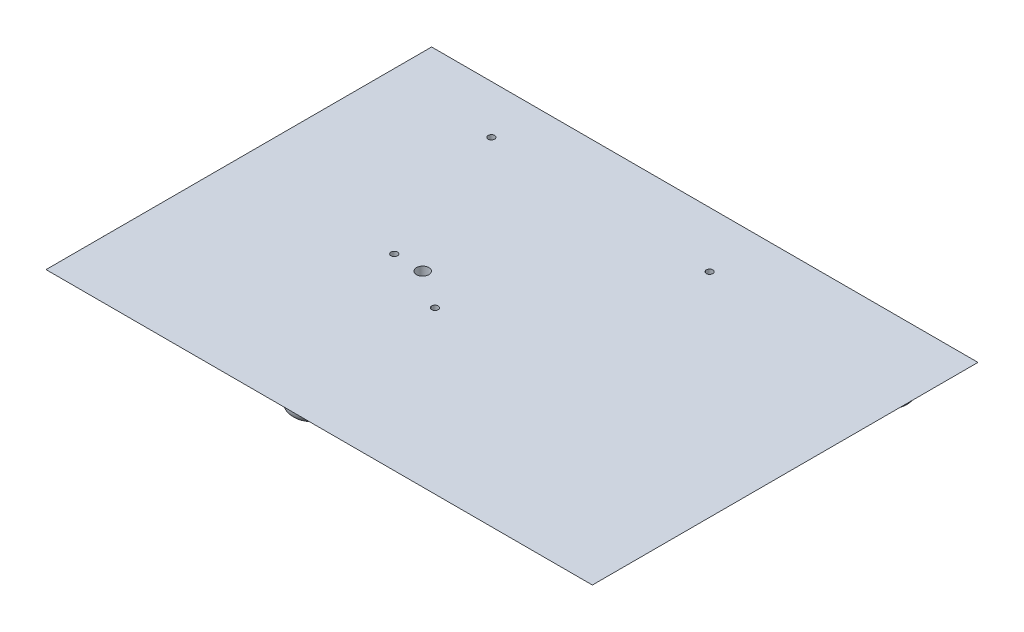
from build123d import *

# Parameters (mm, degrees)
SKETCH3_W           = 260
SKETCH3_H           = 183.5
SKETCH1_W           = 248
SKETCH1_H           = 175
SKETCH1_5_R         = 1.564169695
CUT_EXTRUDE1_DEPTH  = 6
SKETCH1_6_R         = 1.56
SKETCH1_6_R_2       = 2.946919111
CUT_EXTRUDE2_DEPTH  = 6
SKETCH1_7_R         = 1.56
SKETCH1_7_R_2       = 3.675
SKETCH1_7_R_3       = 1.564169695
SKETCH1_7_R_4       = 5.43
SKETCH1_7_R_5       = 2.946919111
BOSS_EXTRUDE2_DEPTH = 1
SKETCH1_9_R         = 1.56
CUT_EXTRUDE9_DEPTH  = 10
SKETCH1_10_R        = 1.563792904
CUT_EXTRUDE11_DEPTH = 10
SKETCH1_11_R        = 9.9
BOSS_EXTRUDE3_DEPTH = 12.5
FILLET1_R           = 5


with BuildPart() as part:
    # Sketch3 → Loft2 section 0
    with BuildSketch(Plane(origin=(0, 6, 0), x_dir=(1, 0, 0), z_dir=(0, 1, 0))):
        with Locations((105.714567309, -62.790792315)):
            Rectangle(SKETCH3_W, SKETCH3_H)
    # Sketch1 → Loft2 section 1
    with BuildSketch(Plane(origin=(0, 0, 0), x_dir=(1, 0, 0), z_dir=(0, 1, 0))):
        with Locations((105.463499551, -60.547933158)):
            Rectangle(SKETCH1_W, SKETCH1_H)
    loft()

    # Sketch1_5 → Cut-Extrude1 (cut)
    with BuildSketch(Plane(origin=(0, 0, 0), x_dir=(1, 0, 0), z_dir=(0, 1, 0))):
        with Locations((52.125403534, -65.240953474)):
            Circle(SKETCH1_5_R)
    extrude(amount=CUT_EXTRUDE1_DEPTH, mode=Mode.SUBTRACT)

    # Sketch1_6 → Cut-Extrude2 (cut)
    with BuildSketch(Plane(origin=(0, 0, 0), x_dir=(1, 0, 0), z_dir=(0, 1, 0))):
        with Locations((27.163499551, 5.952066842)):
            Circle(SKETCH1_6_R)
        with Locations((65.97433474, -65.547933158)):
            Circle(SKETCH1_6_R_2)
    extrude(amount=CUT_EXTRUDE2_DEPTH, mode=Mode.SUBTRACT)

    # Sketch1_7 → Boss-Extrude2 (add)
    with BuildSketch(Plane(origin=(0, 0, 0), x_dir=(1, 0, 0), z_dir=(0, 1, 0))):
        with BuildLine():
            ThreePointArc((30.764919641, 6.683776027), (23.488499551, 5.952066842), (30.764919641, 5.220357657))
            Line((30.764919641, 5.220357657), (30.764919641, 6.683776027))
        make_face()
        with Locations((27.163499551, 5.952066842)):
            Circle(SKETCH1_7_R, mode=Mode.SUBTRACT)
        with Locations((52.125403534, -65.240953474)):
            Circle(SKETCH1_7_R_2)
        with Locations((52.125403534, -65.240953474)):
            Circle(SKETCH1_7_R_3, mode=Mode.SUBTRACT)
        with Locations((65.97433474, -65.547933158)):
            Circle(SKETCH1_7_R_4)
        with Locations((65.97433474, -65.547933158)):
            Circle(SKETCH1_7_R_5, mode=Mode.SUBTRACT)
    extrude(amount=-BOSS_EXTRUDE2_DEPTH)

    # Sketch1_9 → Cut-Extrude9 (cut)
    with BuildSketch(Plane(origin=(0, 0, 0), x_dir=(1, 0, 0), z_dir=(0, 1, 0))):
        with Locations((134.473825947, 2.474049361)):
            Circle(SKETCH1_9_R)
    extrude(amount=CUT_EXTRUDE9_DEPTH, mode=Mode.SUBTRACT)

    # Sketch1_10 → Cut-Extrude11 (cut)
    with BuildSketch(Plane(origin=(0, 0, 0), x_dir=(1, 0, 0), z_dir=(0, 1, 0))):
        with Locations((84.013499551, -77.745508872)):
            Circle(SKETCH1_10_R)
    extrude(amount=CUT_EXTRUDE11_DEPTH, mode=Mode.SUBTRACT)

    # Sketch1_11 → Boss-Extrude3 (add)
    with BuildSketch(Plane(origin=(0, 0, 0), x_dir=(1, 0, 0), z_dir=(0, 1, 0))):
        with Locations((210.683499551, 11.752066842)):
            Circle(SKETCH1_11_R)
        with Locations((78.461853504, -130.95272229)):
            Circle(SKETCH1_11_R)
        with Locations((0.243499551, 11.752066842)):
            Circle(SKETCH1_11_R)
    extrude(amount=-BOSS_EXTRUDE3_DEPTH)

    # Fillet1
    fillet1_edges = [part.edges().sort_by_distance(p)[0] for p in [
        (200.783499551, -12.5, -11.752066842),
        (68.561853504, -12.5, 130.95272229),
        (-9.656500449, -12.5, -11.752066842),
    ]]
    fillet(fillet1_edges, radius=FILLET1_R)


solid = part.part
